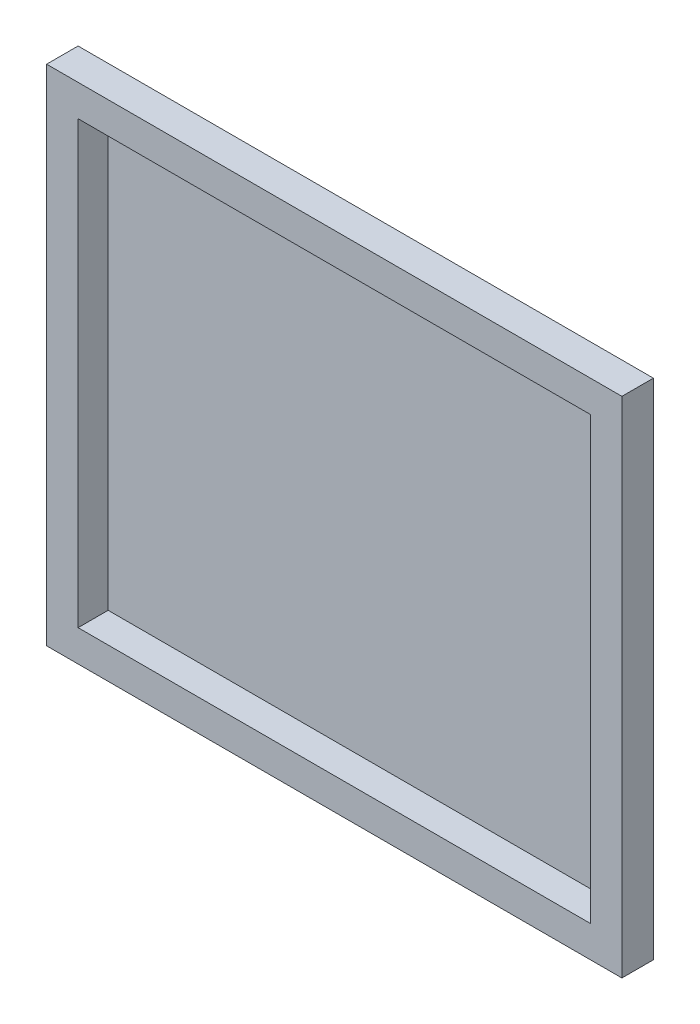
from build123d import *

# Parameters (mm, degrees)
SKETCH_1_W      = 358
SKETCH_1_H      = 308
EXTRUDE_2_DEPTH = 1
SKETCH_1_6_W    = 402
SKETCH_1_6_H    = 352
SKETCH_1_6_W_2  = 358
SKETCH_1_6_H_2  = 308
EXTRUDE_3_DEPTH = 22


with BuildPart() as part:
    # 스케치1 → 보스-돌출2 (new body)
    with BuildSketch(Plane.XY):
        with Locations((201, -176)):
            Rectangle(SKETCH_1_W, SKETCH_1_H)
    extrude(amount=EXTRUDE_2_DEPTH)

    # 스케치1<6> → 보스-돌출3 (add)
    with BuildSketch(Plane.XY):
        with Locations((201, -176)):
            Rectangle(SKETCH_1_6_W, SKETCH_1_6_H)
        with Locations((201, -176)):
            Rectangle(SKETCH_1_6_W_2, SKETCH_1_6_H_2, mode=Mode.SUBTRACT)
    extrude(amount=EXTRUDE_3_DEPTH)


solid = part.part
